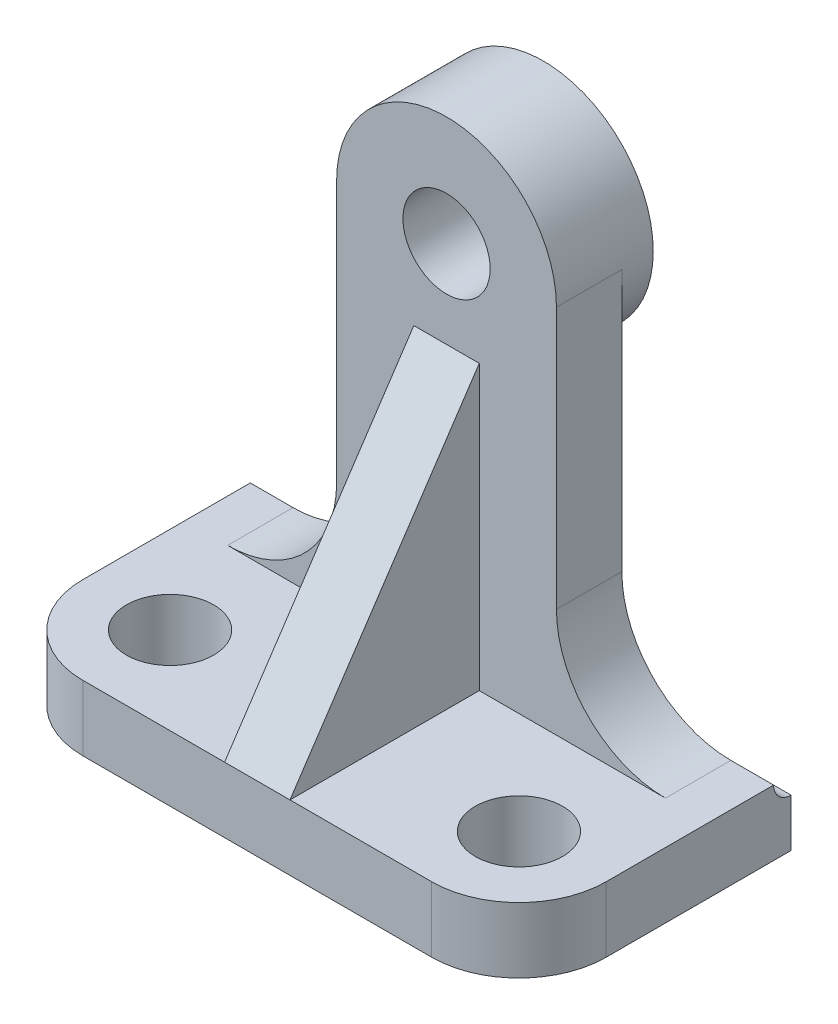
from build123d import *

# Parameters (mm, degrees)
BOSS_EXTRUDE1_DEPTH        = 38.1
BOSS_EXTRUDE2_DEPTH        = 9.525
SKETCH3_R                  = 16.002
BOSS_EXTRUDE3_DEPTH        = 4.572
BOSS_EXTRUDE4_DEPTH        = 4.7625
FILLET1_R                  = 15.875
FILLET2_R                  = 12.7
F_1_4_0_5_DIAMETER_HOLE1_D = 12.7
F_1_4_0_5_DIAMETER_HOLE2_D = 12.7


with BuildPart() as part:
    # Sketch1 → Boss-Extrude1 (new body, symmetric)
    with BuildSketch(Plane(origin=(0, 0, 0), x_dir=(0, 0, -1), z_dir=(1, 0, 0))):
        with BuildLine():
            Line((0, 0), (-37.084, 0))
            Line((-37.084, 0), (-37.084, -9.525))
            Line((-37.084, -9.525), (2.54, -9.525))
            Line((2.54, -9.525), (2.54, -2.54))
            ThreePointArc((2.54, -2.54), (0.743948776, -1.796051224), (0, 0))
        make_face()
    extrude(amount=BOSS_EXTRUDE1_DEPTH, both=True)

    # Sketch2 → Boss-Extrude2 (add)
    with BuildSketch(Plane.XY):
        with BuildLine():
            Line((-16.002, 0), (16.002, 0))
            Line((16.002, 0), (16.002, 53.975))
            ThreePointArc((16.002, 53.975), (0, 69.977), (-16.002, 53.975))
            Line((-16.002, 53.975), (-16.002, 0))
        make_face()
    extrude(amount=BOSS_EXTRUDE2_DEPTH)

    # Sketch3 → Boss-Extrude3 (add)
    with BuildSketch(Plane(origin=(0, 0, 0), x_dir=(-1, 0, 0), z_dir=(0, 0, -1))):
        with Locations((0, 53.975)):
            Circle(SKETCH3_R)
    extrude(amount=BOSS_EXTRUDE3_DEPTH)

    # Sketch4 → Boss-Extrude4 (add, symmetric)
    with BuildSketch(Plane(origin=(0, 0, 0), x_dir=(0, 0, -1), z_dir=(1, 0, 0))):
        Polygon((-9.525, 41.275), (-37.084, 0), (-9.525, 0), align=None)
    extrude(amount=BOSS_EXTRUDE4_DEPTH, both=True)

    # Fillet1
    fillet1_edges = [part.edges().sort_by_distance(p)[0] for p in [
        (-16.002, 0, 4.7625),
        (16.002, 0, 4.7625),
    ]]
    fillet(fillet1_edges, radius=FILLET1_R)

    # Fillet2
    fillet2_edges = [part.edges().sort_by_distance(p)[0] for p in [
        (38.1, -4.7625, 37.084),
        (-38.1, -4.7625, 37.084),
    ]]
    fillet(fillet2_edges, radius=FILLET2_R)

    # 1_4 _0.5_ Diameter Hole1 (through all)
    with Locations(Plane(origin=(0, 0, 0), x_dir=(1, 0, 0), z_dir=(0, 1, 0))):
        with Locations((-25.4, -24.384), (25.4, -24.384)):
            Hole(F_1_4_0_5_DIAMETER_HOLE1_D / 2)

    # 1_4 _0.5_ Diameter Hole2 (through all)
    with Locations(Plane.XY.offset(9.525)):
        with Locations((0, 53.975)):
            Hole(F_1_4_0_5_DIAMETER_HOLE2_D / 2)


solid = part.part
